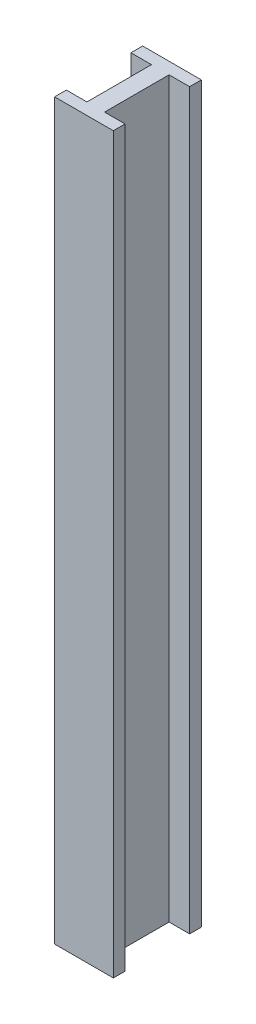
from build123d import *

# Parameters (mm, degrees)
BOSS_EXTRUDE1_DEPTH = 500


with BuildPart() as part:
    # Sketch1 → Boss-Extrude1 (new body)
    with BuildSketch(Plane(origin=(0, 0, 0), x_dir=(1, 0, 0), z_dir=(0, 1, 0))):
        Polygon((0, 0), (0, 44), (-14, 44), (-14, 52), (26, 52), (26, 44), (12, 44), (12, 0), (26, 0), (26, -8), (-14, -8), (-14, 0), align=None)
    extrude(amount=BOSS_EXTRUDE1_DEPTH)


solid = part.part
